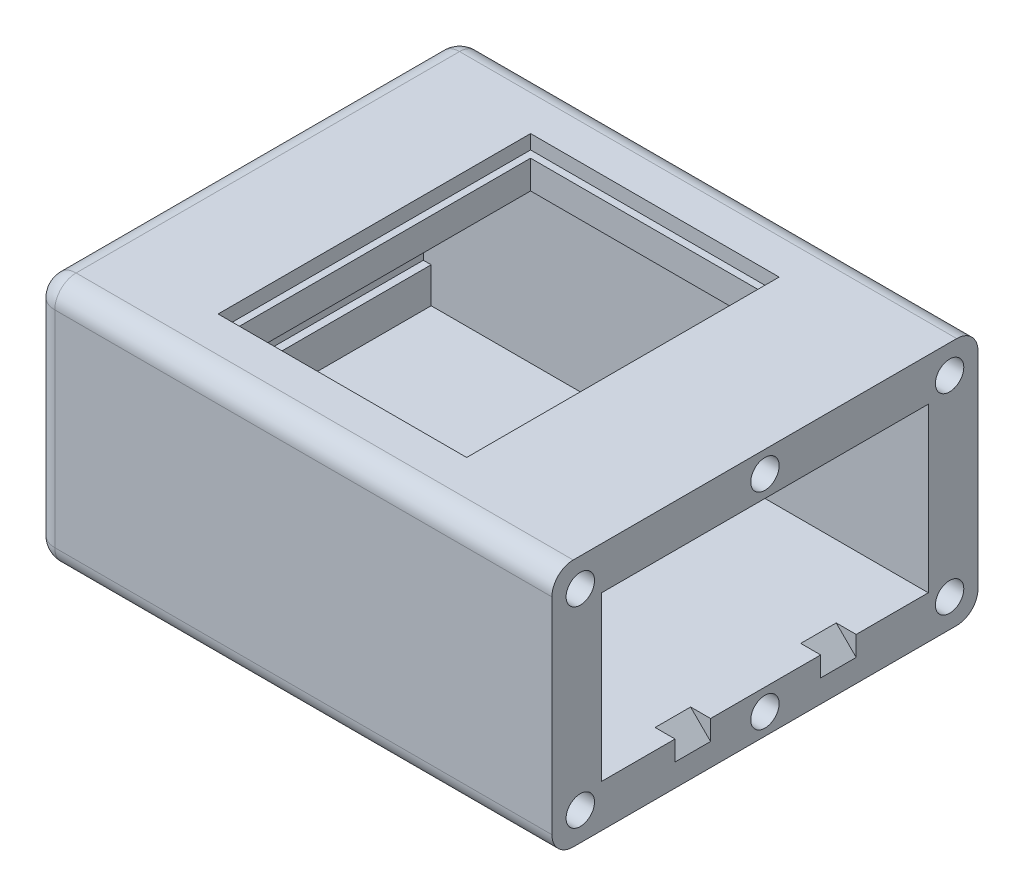
from build123d import *

# Parameters (mm, degrees)
SKETCH1_W               = 60
SKETCH1_H               = 35
SKETCH1_W_2             = 46
SKETCH1_H_2             = 23
BOSS_EXTRUDE1_DEPTH     = 73
SKETCH2_W               = 46
SKETCH2_H               = 23
BOSS_EXTRUDE2_DEPTH     = 3
SKETCH1_3_R             = 2
CUT_EXTRUDE1_DEPTH      = 4.8
FILLET1_R               = 3
SKETCH3_W               = 46
SKETCH3_H               = 2.5
CUT_EXTRUDE2_DEPTH      = 1.1
SKETCH5_W               = 33
SKETCH5_H               = 42
CUT_EXTRUDE5_DEPTH      = 10
SKETCH5_3_W             = 35
SKETCH5_3_H             = 44
SKETCH5_3_W_2           = 33
SKETCH5_3_H_2           = 42
CUT_EXTRUDE6_DEPTH      = 2
CUT_EXTRUDE8_DEPTH      = 0.5
CUT_EXTRUDE8_DEPTH_BACK = 4.5
CUT_EXTRUDE9_DEPTH      = 0.5
CUT_EXTRUDE9_DEPTH_BACK = 4.5


with BuildPart() as part:
    # Sketch1 → Boss-Extrude1 (new body)
    with BuildSketch(Plane(origin=(0, 0, 0), x_dir=(0, 0, -1), z_dir=(1, 0, 0))):
        Rectangle(SKETCH1_W, SKETCH1_H)
        Rectangle(SKETCH1_W_2, SKETCH1_H_2, mode=Mode.SUBTRACT)
    extrude(amount=-BOSS_EXTRUDE1_DEPTH)

    # Sketch2 → Boss-Extrude2 (add)
    with BuildSketch(Plane.ZY.offset(73)):
        Rectangle(SKETCH2_W, SKETCH2_H)
    extrude(amount=-BOSS_EXTRUDE2_DEPTH)

    # Sketch1_3 → Cut-Extrude1 (cut)
    with BuildSketch(Plane(origin=(0, 0, 0), x_dir=(0, 0, -1), z_dir=(1, 0, 0))):
        with Locations((-26, 13.5)):
            Circle(SKETCH1_3_R)
        with Locations((0, 14.5)):
            Circle(SKETCH1_3_R)
        with Locations((26, 13.5)):
            Circle(SKETCH1_3_R)
        with Locations((0, -14.5)):
            Circle(SKETCH1_3_R)
        with Locations((-26, -13.5)):
            Circle(SKETCH1_3_R)
        with Locations((26, -13.5)):
            Circle(SKETCH1_3_R)
    extrude(amount=-CUT_EXTRUDE1_DEPTH, mode=Mode.SUBTRACT)

    # Fillet1
    fillet1_edges = [part.edges().sort_by_distance(p)[0] for p in [
        (-73, 17.5, 0),
        (-73, 0, 30),
        (-73, -17.5, 0),
        (-73, 0, -30),
        (-36.5, -17.5, 30),
        (-36.5, 17.5, 30),
        (-36.5, 17.5, -30),
        (-36.5, -17.5, -30),
    ]]
    fillet(fillet1_edges, radius=FILLET1_R)

    # Sketch3 → Cut-Extrude2 (cut)
    with BuildSketch(Plane(origin=(-70, 0, 0), x_dir=(0, 0, -1), z_dir=(1, 0, 0))):
        with Locations((0, -5.25)):
            Rectangle(SKETCH3_W, SKETCH3_H)
    extrude(amount=-CUT_EXTRUDE2_DEPTH, mode=Mode.SUBTRACT)

    # Sketch5 → Cut-Extrude5 (cut)
    with BuildSketch(Plane(origin=(0, 17.5, 0), x_dir=(1, 0, 0), z_dir=(0, 1, 0))):
        with Locations((-37.5, 0)):
            Rectangle(SKETCH5_W, SKETCH5_H)
    extrude(amount=-CUT_EXTRUDE5_DEPTH, mode=Mode.SUBTRACT)

    # Sketch5_3 → Cut-Extrude6 (cut)
    with BuildSketch(Plane(origin=(0, 17.5, 0), x_dir=(1, 0, 0), z_dir=(0, 1, 0))):
        with Locations((-37.5, 0)):
            Rectangle(SKETCH5_3_W, SKETCH5_3_H)
        with Locations((-37.5, 0)):
            Rectangle(SKETCH5_3_W_2, SKETCH5_3_H_2, mode=Mode.SUBTRACT)
    extrude(amount=-CUT_EXTRUDE6_DEPTH, mode=Mode.SUBTRACT)

    # Sketch7 → Cut-Extrude8 (cut, two sides)
    with BuildSketch(Plane.XY.offset(12.159)) as cut_extrude8_sk:
        Polygon((0, -11), (0, -14.307106781), (-3.307106781, -11), align=None)
    extrude(amount=CUT_EXTRUDE8_DEPTH, mode=Mode.SUBTRACT)
    extrude(cut_extrude8_sk.sketch, amount=-CUT_EXTRUDE8_DEPTH_BACK, mode=Mode.SUBTRACT)

    # Sketch8 → Cut-Extrude9 (cut, two sides)
    with BuildSketch(Plane(origin=(0, 0, -12.345376068), x_dir=(-1, 0, 0), z_dir=(0, 0, -1))) as cut_extrude9_sk:
        Polygon((0, -11), (3.307106781, -11), (0, -14.307106781), align=None)
    extrude(amount=CUT_EXTRUDE9_DEPTH, mode=Mode.SUBTRACT)
    extrude(cut_extrude9_sk.sketch, amount=-CUT_EXTRUDE9_DEPTH_BACK, mode=Mode.SUBTRACT)


solid = part.part
